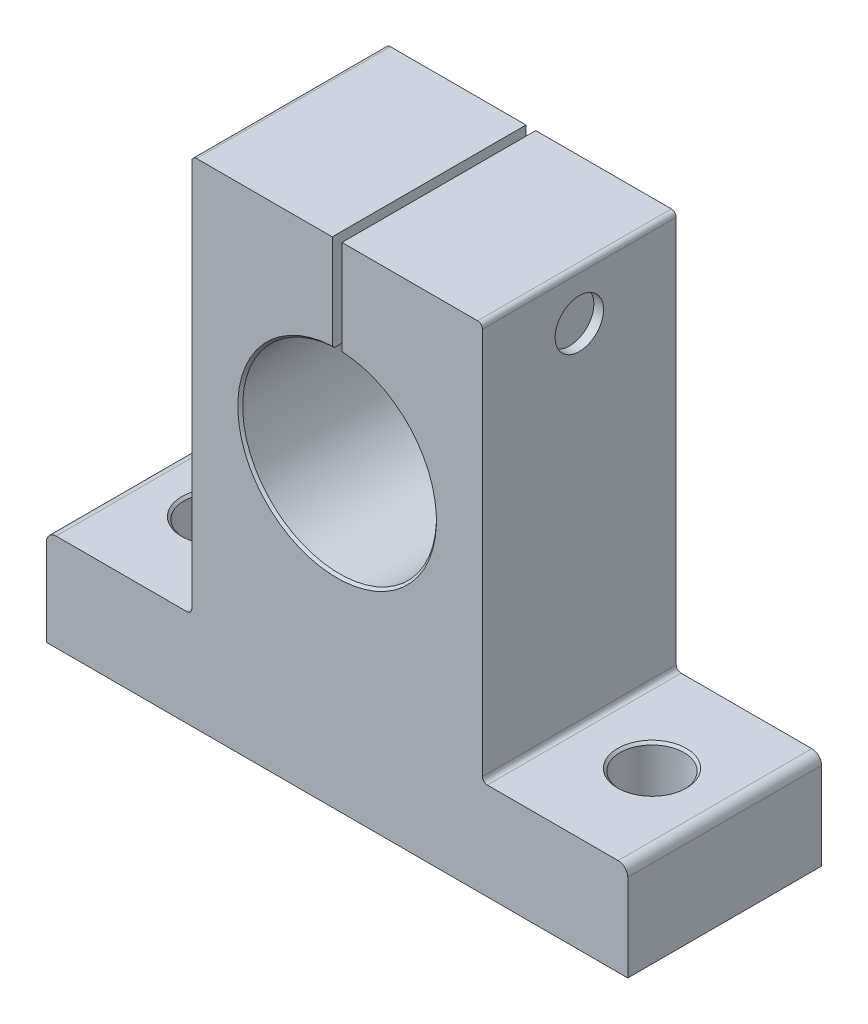
from build123d import *

# Parameters (mm, degrees)
BOSS_EXTRUDE1_DEPTH     = 20
SKETCH3_R               = 3.3
CUT_EXTRUDE1_DEPTH      = 1
CUT_EXTRUDE1_DEPTH_BACK = 10
FILLET1_R               = 1
FILLET2_R               = 0.5
CHAMFER1_SIZE           = 0.25
SKETCH4_R               = 3.85
CUT_EXTRUDE2_DEPTH      = 1
SKETCH5_R               = 3.85
SKETCH5_R_2             = 3.75
CUT_EXTRUDE3_DEPTH      = 5
CHAMFER2_SIZE           = 0.25
CUT_EXTRUDE4_DEPTH      = 2.5
SKETCH7_R               = 2.5
BOSS_EXTRUDE2_DEPTH     = 1
SKETCH8_R               = 2.5
CUT_EXTRUDE5_DEPTH      = 1
SKETCH9_R               = 2.165063509
CUT_EXTRUDE6_DEPTH      = 1
CUT_EXTRUDE6_TAPER      = 45


with BuildPart() as part:
    # Sketch1 → Boss-Extrude1 (new body)
    with BuildSketch(Plane.XY):
        with BuildLine():
            Line((-30, 0), (30, 0))
            Line((30, 0), (30, 10))
            Line((30, 10), (15, 10))
            Line((15, 10), (15, 51))
            Line((15, 51), (0.5, 51))
            Line((0.5, 51), (0.5, 40.987492178))
            ThreePointArc((0.5, 40.987492178), (0, 21), (-0.5, 40.987492178))
            Line((-0.5, 40.987492178), (-0.5, 51))
            Line((-0.5, 51), (-15, 51))
            Line((-15, 51), (-15, 10))
            Line((-15, 10), (-30, 10))
            Line((-30, 10), (-30, 0))
        make_face()
    extrude(amount=BOSS_EXTRUDE1_DEPTH)

    # Sketch3 → Cut-Extrude1 (cut, two sides)
    with BuildSketch(Plane.XZ) as cut_extrude1_sk:
        with Locations((-22.5, 10)):
            Circle(SKETCH3_R)
        with Locations((22.5, 10)):
            Circle(SKETCH3_R)
    extrude(amount=CUT_EXTRUDE1_DEPTH, mode=Mode.SUBTRACT)
    extrude(cut_extrude1_sk.sketch, amount=-CUT_EXTRUDE1_DEPTH_BACK, mode=Mode.SUBTRACT)

    # Fillet1
    fillet1_edges = [part.edges().sort_by_distance(p)[0] for p in [
        (-30, 10, 10),
        (30, 10, 10),
    ]]
    fillet(fillet1_edges, radius=FILLET1_R)

    # Fillet2
    fillet2_edges = [part.edges().sort_by_distance(p)[0] for p in [
        (-15, 10, 10),
        (-15, 51, 10),
        (15, 51, 10),
        (15, 10, 10),
    ]]
    fillet(fillet2_edges, radius=FILLET2_R)

    # Chamfer1
    chamfer1_edges = [part.edges().sort_by_distance(p)[0] for p in [
        (0, 21, 0),
        (0, 21, 20),
        (19.2, 10, 10),
        (19.2, 0, 10),
        (-25.8, 10, 10),
        (-25.8, 0, 10),
    ]]
    chamfer(chamfer1_edges, length=CHAMFER1_SIZE)

    # Sketch4 → Cut-Extrude2 (cut)
    with BuildSketch(Plane.ZY.offset(15)):
        with Locations((10, 46)):
            Circle(SKETCH4_R)
    extrude(amount=-CUT_EXTRUDE2_DEPTH, mode=Mode.SUBTRACT)

    # Sketch5 → Cut-Extrude3 (cut)
    with BuildSketch(Plane.ZY.offset(14)):
        with Locations((10, 46)):
            Circle(SKETCH5_R)
        with Locations((10, 46)):
            Circle(SKETCH5_R_2, mode=Mode.SUBTRACT)
    extrude(amount=-CUT_EXTRUDE3_DEPTH, mode=Mode.SUBTRACT)

    # Chamfer2
    chamfer2_edges = [part.edges().sort_by_distance(p)[0] for p in [
        (-14, 46, 6.25),
    ]]
    chamfer(chamfer2_edges, length=CHAMFER2_SIZE)

    # Sketch6 → Cut-Extrude4 (cut)
    with BuildSketch(Plane.ZY.offset(14)):
        Polygon((9.85568838, 43.839751367), (11.798674385, 44.794898154), (11.942986005, 46.955146787), (10.14431162, 48.160248633), (8.201325615, 47.205101846), (8.057013995, 45.044853213), align=None)
    extrude(amount=-CUT_EXTRUDE4_DEPTH, mode=Mode.SUBTRACT)

    # Sketch7 → Boss-Extrude2 (add)
    with BuildSketch(Plane(origin=(-0.5, 0, 0), x_dir=(0, 0, -1), z_dir=(1, 0, 0))):
        with Locations((-10, 46)):
            Circle(SKETCH7_R)
    extrude(amount=BOSS_EXTRUDE2_DEPTH)

    # Sketch8 → Cut-Extrude5 (cut)
    with BuildSketch(Plane(origin=(15, 0, 0), x_dir=(0, 0, -1), z_dir=(1, 0, 0))):
        with Locations((-10, 46)):
            Circle(SKETCH8_R)
    extrude(amount=-CUT_EXTRUDE5_DEPTH, mode=Mode.SUBTRACT)

    # Sketch9 → Cut-Extrude6 (cut)
    with BuildSketch(Plane.ZY.offset(14)):
        with Locations((10, 46)):
            Circle(SKETCH9_R)
    extrude(amount=-CUT_EXTRUDE6_DEPTH, taper=CUT_EXTRUDE6_TAPER, mode=Mode.SUBTRACT)


solid = part.part
